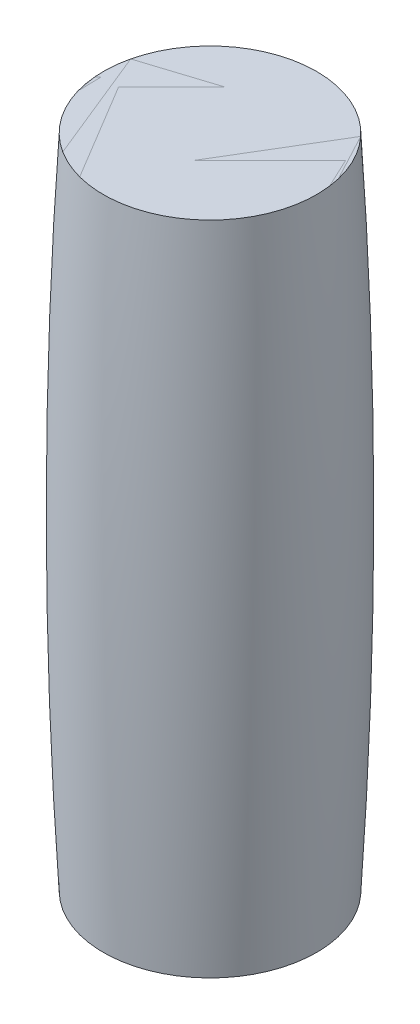
from build123d import *

# Parameters (mm, degrees)
SCHIZZO2_R                   = 65
ESTRUSIONE_ESTRUSIONE1_DEPTH = 400


with BuildPart() as part:
    # Schizzo1 → Rivoluzione1 (revolve)
    with BuildSketch(Plane.XY):
        with BuildLine():
            Line((0, 0), (-65, 0))
            ThreePointArc((-65, 0), (-70.561279316, 200), (-65, 400))
            Line((-65, 400), (0, 400))
            Line((0, 400), (0, 0))
        make_face()
    revolve(axis=Axis((0, 0, 0), (0, 1, 0)))


with BuildPart() as body_2:
    # Schizzo2 → Estrusione-Estrusione1 (new body)
    with BuildSketch(Plane.XZ):
        Circle(SCHIZZO2_R)
    extrude(amount=-ESTRUSIONE_ESTRUSIONE1_DEPTH)


solid = Compound([part.part, body_2.part])
